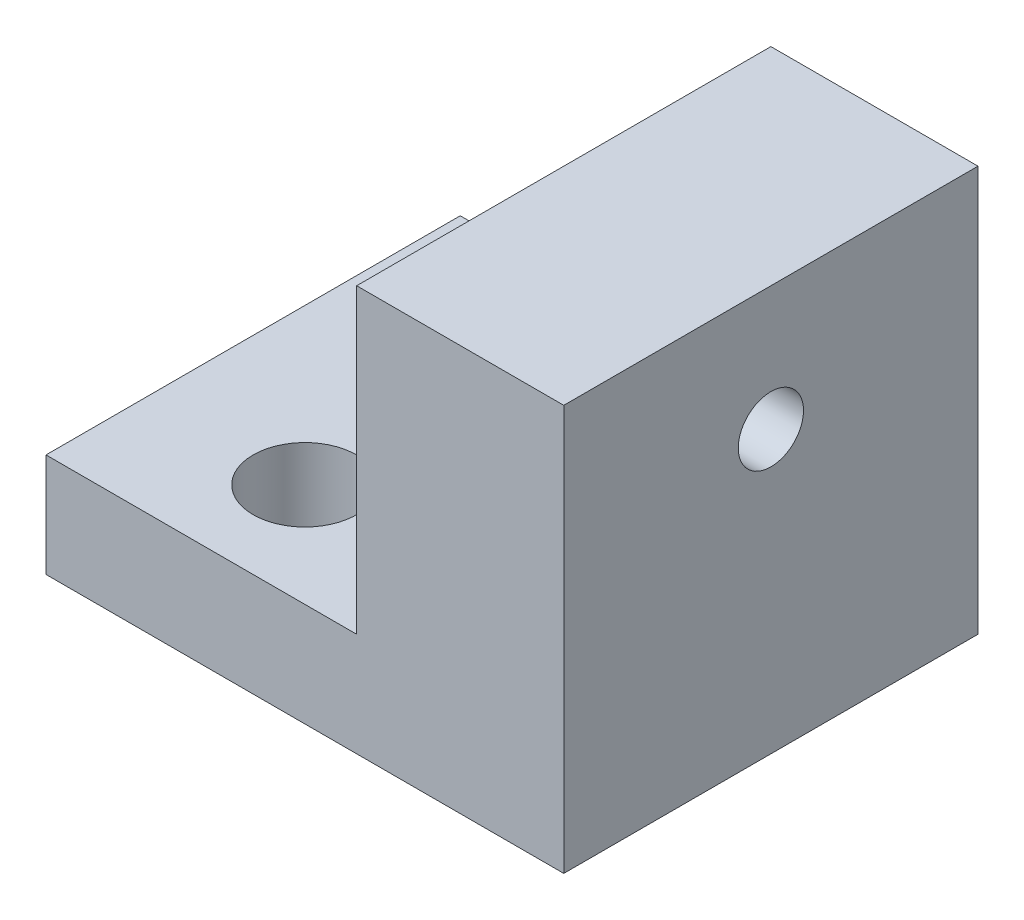
from build123d import *

# Parameters (mm, degrees)
SKETCH1_W           = 19.05
SKETCH1_H           = 6.35
SKETCH1_W_2         = 12.7
SKETCH1_H_2         = 38.1
BOSS_EXTRUDE1_DEPTH = 25.4
CUT_EXTRUDE1_REACH  = 8.35
SKETCH2_R           = 3.175
CUT_EXTRUDE2_REACH  = 33.75
SKETCH3_R           = 2
CUT_EXTRUDE3_REACH  = 33.75
SKETCH4_W           = 25.4
SKETCH4_H           = 13.240999966


with BuildPart() as part:
    # Sketch1 → Boss-Extrude1 (new body)
    with BuildSketch(Plane.XY):
        with Locations((-15.875, -15.875)):
            Rectangle(SKETCH1_W, SKETCH1_H)
        Rectangle(SKETCH1_W_2, SKETCH1_H_2)
    extrude(amount=BOSS_EXTRUDE1_DEPTH)

    # Sketch2 → Cut-Extrude1 (cut, up to next)
    with BuildSketch(Plane(origin=(0, -12.7, 0), x_dir=(1, 0, 0), z_dir=(0, 1, 0)), mode=Mode.PRIVATE) as cut_extrude1_sk1:
        with Locations((-15.875, -6.35)):
            Circle(SKETCH2_R)
    cut_extrude1_tool1 = extrude(cut_extrude1_sk1.sketch, amount=-CUT_EXTRUDE1_REACH, mode=Mode.PRIVATE) & part.part
    add(cut_extrude1_tool1.solids().sort_by_distance((-15.875, -12.7, 6.35))[0], mode=Mode.SUBTRACT)
    # Sketch2 → Cut-Extrude1 (cut, up to next)
    with BuildSketch(Plane(origin=(0, -12.7, 0), x_dir=(1, 0, 0), z_dir=(0, 1, 0)), mode=Mode.PRIVATE) as cut_extrude1_sk2:
        with Locations((-15.875, -19.05)):
            Circle(SKETCH2_R)
    cut_extrude1_tool2 = extrude(cut_extrude1_sk2.sketch, amount=-CUT_EXTRUDE1_REACH, mode=Mode.PRIVATE) & part.part
    add(cut_extrude1_tool2.solids().sort_by_distance((-15.875, -12.7, 19.05))[0], mode=Mode.SUBTRACT)

    # Sketch3 → Cut-Extrude2 (cut, up to next)
    with BuildSketch(Plane(origin=(6.35, 0, 0), x_dir=(0, 0, -1), z_dir=(1, 0, 0)), mode=Mode.PRIVATE) as cut_extrude2_sk1:
        with Locations((-12.7, -1.810999966)):
            Circle(SKETCH3_R)
    cut_extrude2_tool1 = extrude(cut_extrude2_sk1.sketch, amount=-CUT_EXTRUDE2_REACH, mode=Mode.PRIVATE) & part.part
    add(cut_extrude2_tool1.solids().sort_by_distance((6.35, -1.811, 12.7))[0], mode=Mode.SUBTRACT)

    # Sketch4 → Cut-Extrude3 (cut, up to next)
    with BuildSketch(Plane(origin=(6.35, 0, 0), x_dir=(0, 0, -1), z_dir=(1, 0, 0)), mode=Mode.PRIVATE) as cut_extrude3_sk1:
        with Locations((-12.7, 12.429500017)):
            Rectangle(SKETCH4_W, SKETCH4_H)
    cut_extrude3_tool1 = extrude(cut_extrude3_sk1.sketch, amount=-CUT_EXTRUDE3_REACH, mode=Mode.PRIVATE) & part.part
    add(cut_extrude3_tool1.solids().sort_by_distance((6.35, 12.4295, 12.7))[0], mode=Mode.SUBTRACT)


solid = part.part
